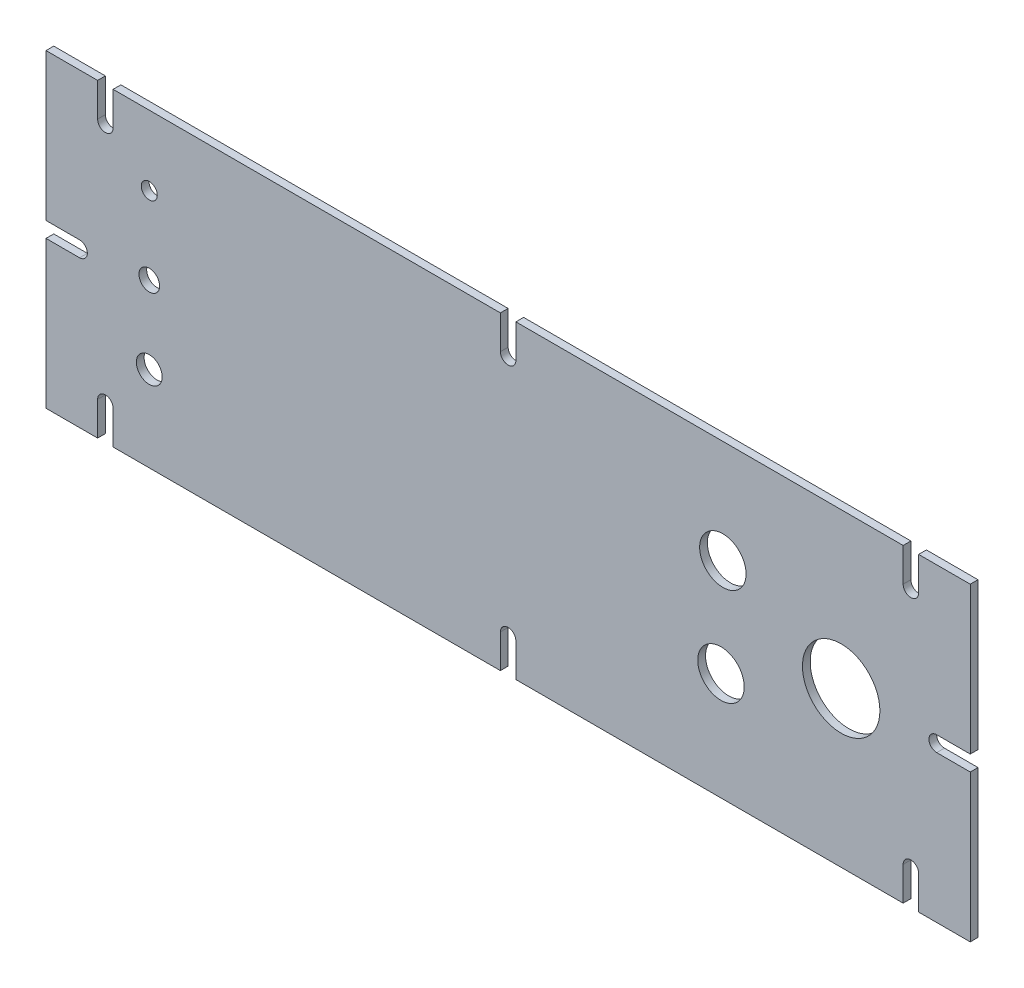
from build123d import *

# Parameters (mm, degrees)
SKETCH1_W           = 358
SKETCH1_H           = 120
BOSS_EXTRUDE1_DEPTH = 3
SKETCH2_R           = 15
SKETCH2_R_2         = 9
CUT_EXTRUDE1_DEPTH  = 10
SKETCH3_R           = 3.1
SKETCH3_R_2         = 4
SKETCH3_R_3         = 5
CUT_EXTRUDE2_DEPTH  = 10
CUT_EXTRUDE3_DEPTH  = 10


with BuildPart() as part:
    # Sketch1 → Boss-Extrude1 (new body)
    with BuildSketch(Plane.XY):
        Rectangle(SKETCH1_W, SKETCH1_H)
    extrude(amount=BOSS_EXTRUDE1_DEPTH)

    # Sketch2 → Cut-Extrude1 (cut)
    with BuildSketch(Plane.XY.offset(3)):
        with Locations((129, 0)):
            Circle(SKETCH2_R)
        with Locations((83.17424305, 20)):
            Circle(SKETCH2_R_2)
        with Locations((82.45294449, -18.261544956)):
            Circle(SKETCH2_R_2)
    extrude(amount=-CUT_EXTRUDE1_DEPTH, mode=Mode.SUBTRACT)

    # Sketch3 → Cut-Extrude2 (cut)
    with BuildSketch(Plane.XY.offset(3)):
        with Locations((-139, 33)):
            Circle(SKETCH3_R)
        with Locations((-139, 3)):
            Circle(SKETCH3_R_2)
        with Locations((-139, -27)):
            Circle(SKETCH3_R_3)
    extrude(amount=-CUT_EXTRUDE2_DEPTH, mode=Mode.SUBTRACT)

    # Sketch4 → Cut-Extrude3 (cut)
    with BuildSketch(Plane.XY.offset(3)):
        with BuildLine():
            Line((-159, -60), (-159, -47))
            ThreePointArc((-159, -47), (-156, -44), (-153, -47))
            Line((-153, -47), (-153, -60))
            Line((-153, -60), (-159, -60))
        make_face()
        with BuildLine():
            Line((-153, 47), (-153, 60))
            Line((-153, 60), (-159, 60))
            Line((-159, 60), (-159, 47))
            ThreePointArc((-159, 47), (-156, 44), (-153, 47))
        make_face()
        with BuildLine():
            Line((159, 60), (159, 47))
            ThreePointArc((159, 47), (156, 44), (153, 47))
            Line((153, 47), (153, 60))
            Line((153, 60), (159, 60))
        make_face()
        with BuildLine():
            Line((153, -47), (153, -60))
            Line((153, -60), (159, -60))
            Line((159, -60), (159, -47))
            ThreePointArc((159, -47), (156, -44), (153, -47))
        make_face()
        with BuildLine():
            Line((-179, 3), (-166, 3))
            ThreePointArc((-166, 3), (-163, 0), (-166, -3))
            Line((-166, -3), (-179, -3))
            Line((-179, -3), (-179, 3))
        make_face()
        with BuildLine():
            Line((-3, -60), (-3, -47))
            ThreePointArc((-3, -47), (0, -44), (3, -47))
            Line((3, -47), (3, -60))
            Line((3, -60), (-3, -60))
        make_face()
        with BuildLine():
            Line((166, -3), (179, -3))
            Line((179, -3), (179, 3))
            Line((179, 3), (166, 3))
            ThreePointArc((166, 3), (163, 0), (166, -3))
        make_face()
        with BuildLine():
            Line((3, 47), (3, 60))
            Line((3, 60), (-3, 60))
            Line((-3, 60), (-3, 47))
            ThreePointArc((-3, 47), (0, 44), (3, 47))
        make_face()
    extrude(amount=-CUT_EXTRUDE3_DEPTH, mode=Mode.SUBTRACT)


solid = part.part
